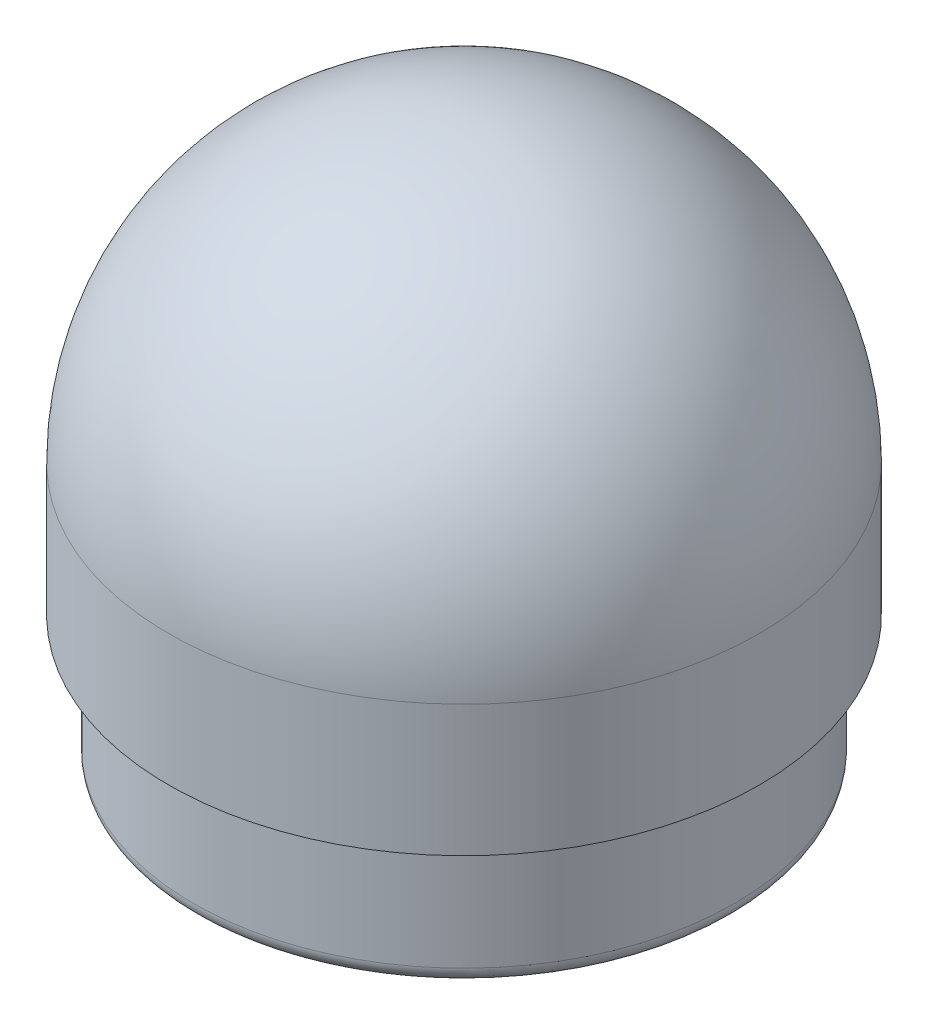
from build123d import *


with BuildPart() as part:
    # Sketch2 → Revolve1 (revolve)
    with BuildSketch(Plane.XY):
        with BuildLine():
            Line((44.45, 0), (49.2125, 0))
            ThreePointArc((49.2125, 0), (51.45756403, 0.92993597), (52.3875, 3.175))
            Line((52.3875, 3.175), (52.3875, 25.4))
            Line((52.3875, 25.4), (57.15, 25.4))
            Line((57.15, 25.4), (57.15, 50.8))
            ThreePointArc((57.15, 50.8), (40.411152545, 91.211152545), (0, 107.95))
            Line((0, 107.95), (0, 95.25))
            ThreePointArc((0, 95.25), (31.430896424, 82.230896424), (44.45, 50.8))
            Line((44.45, 50.8), (44.45, 0))
        make_face()
    revolve(axis=Axis((0, 107.95, 0), (0, -1, 0)))


solid = part.part
